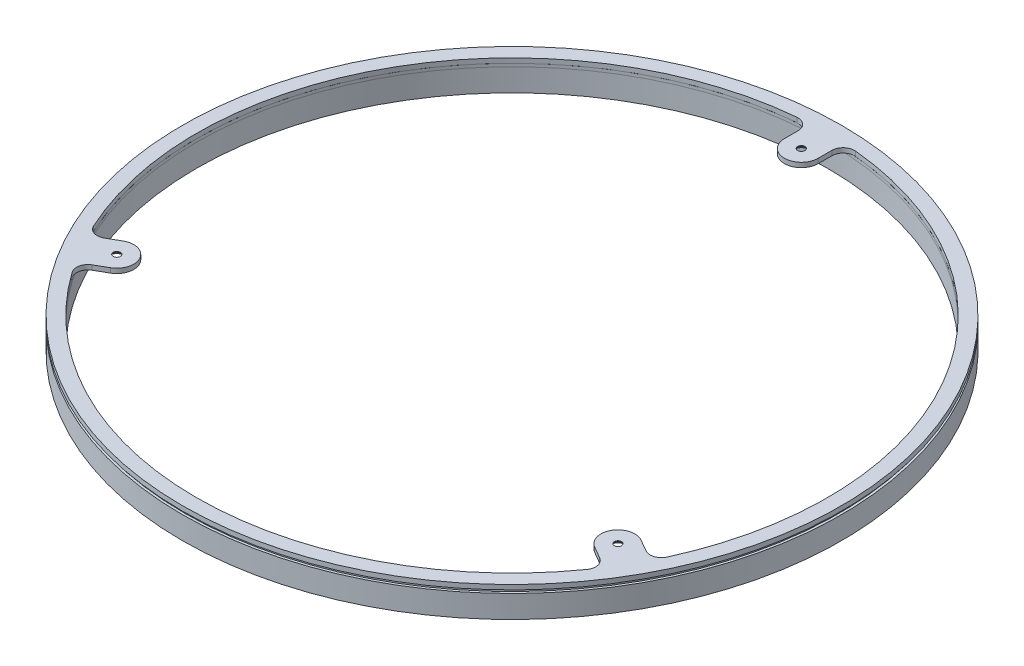
from build123d import *

# Parameters (mm, degrees)
SKETCH1_R                = 145.86
SKETCH1_R_2              = 139.67
BOSS_EXTRUDE1_DEPTH      = 2.07456
SKETCH6_R                = 144.84
SKETCH6_R_2              = 139.67
BOSS_EXTRUDE3_DEPTH      = 1.34313
SKETCH7_R                = 145.88
SKETCH7_R_2              = 139.67
BOSS_EXTRUDE4_DEPTH      = 10
BOSS_EXTRUDE5_DEPTH      = 2.07456
FILLET1_R                = 5
CIRPATTERN1_COUNT        = 3
CIRPATTERN1_2_COUNT      = 3
FILLET1_OF_CIRPATTERN1_R = 5


with BuildPart() as part:
    # Sketch1 → Boss-Extrude1 (new body)
    with BuildSketch(Plane(origin=(0, 0, 0), x_dir=(1, 0, 0), z_dir=(0, 1, 0))):
        Circle(SKETCH1_R)
        Circle(SKETCH1_R_2, mode=Mode.SUBTRACT)
    extrude(amount=BOSS_EXTRUDE1_DEPTH)

    # Sketch8 → Boss-Extrude5 (add)
    with BuildSketch(Plane(origin=(0, 0, 0), x_dir=(1, 0, 0), z_dir=(0, 1, 0))):
        with BuildLine():
            Line((-7.5, 128.0625), (-7.5, 139.468487122))
            ThreePointArc((-7.5, 139.468487122), (0, 139.67), (7.5, 139.468487122))
            Line((7.5, 139.468487122), (7.5, 128.0625))
            ThreePointArc((7.5, 128.0625), (0, 120.5625), (-7.5, 128.0625))
        make_face()
    boss_extrude5 = extrude(amount=BOSS_EXTRUDE5_DEPTH)

    # Fillet1
    fillet1_edges = [part.edges().sort_by_distance(p)[0] for p in [
        (7.5, 1.03728, -139.468487122),
        (-7.5, 1.03728, -139.468487122),
    ]]
    fillet(fillet1_edges, radius=FILLET1_R)

    # Sketch12 → CSK for M3 Countersunk Flat Head Screw1 (revolve, cut)
    with BuildSketch(Plane(origin=(0, 0, -128.0625), x_dir=(0, 0, -1), z_dir=(1, 0, 0))):
        Polygon((0, 0), (0, 2.07456), (1.6, 2.07456), (1.6, 1.75), (3.35, 0), align=None)
    csk_for_m3_countersunk_flat_head_screw1 = revolve(axis=Axis((0, -6.35, -128.0625), (0, 1, 0)), mode=Mode.SUBTRACT)

    # CirPattern1: Boss-Extrude5 ×3 about axis
    cirpattern1_axis = Axis((0, 0, 0), (0, 1, 0))
    for i in range(1, CIRPATTERN1_COUNT):
        add(boss_extrude5.rotate(cirpattern1_axis, i * 360 / CIRPATTERN1_COUNT))

    # CirPattern1 2: CSK for M3 Countersunk Flat Head Screw1 ×3 about axis
    cirpattern1_2_axis = Axis((0, 0, 0), (0, 1, 0))
    for i in range(1, CIRPATTERN1_2_COUNT):
        add(csk_for_m3_countersunk_flat_head_screw1.rotate(cirpattern1_2_axis, i * 360 / CIRPATTERN1_2_COUNT), mode=Mode.SUBTRACT)

    # Fillet1 of CirPattern1
    fillet1_of_cirpattern1_edges = [part.edges().sort_by_distance(p)[0] for p in [
        (-124.533252875, 1.03728, 63.239053032),
        (-117.033252875, 1.03728, 76.229434089),
        (117.033252875, 1.03728, 76.229434089),
        (124.533252875, 1.03728, 63.239053032),
    ]]
    fillet(fillet1_of_cirpattern1_edges, radius=FILLET1_OF_CIRPATTERN1_R)


with BuildPart() as body_2:
    # Sketch6 → Boss-Extrude3 (new body)
    with BuildSketch(Plane.XZ):
        Circle(SKETCH6_R)
        Circle(SKETCH6_R_2, mode=Mode.SUBTRACT)
    extrude(amount=BOSS_EXTRUDE3_DEPTH)


with BuildPart() as body_3:
    # Sketch7 → Boss-Extrude4 (new body)
    with BuildSketch(Plane.XZ.offset(1.34313)):
        Circle(SKETCH7_R)
        Circle(SKETCH7_R_2, mode=Mode.SUBTRACT)
    extrude(amount=BOSS_EXTRUDE4_DEPTH)


solid = Compound([part.part, body_2.part, body_3.part])
